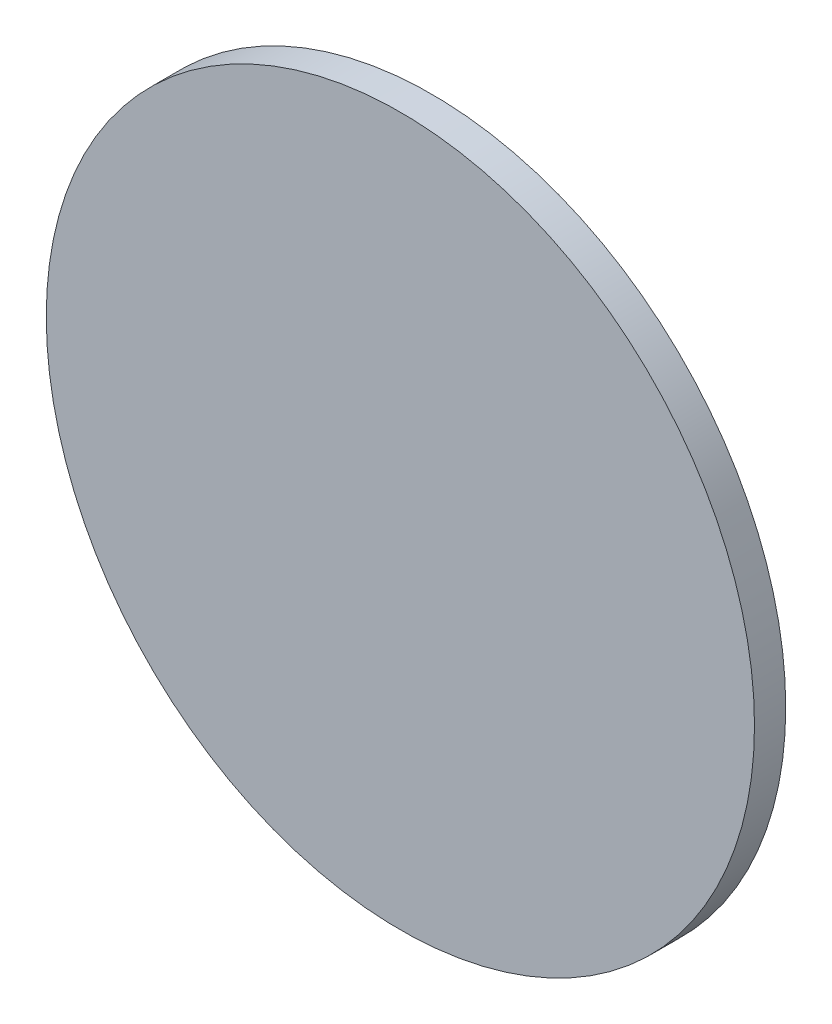
from build123d import *

# Parameters (mm, degrees)
SKETCH1_R                = 85
BOSS_EXTRUDE1_DEPTH      = 7.5
CUT_EXTRUDE1_DEPTH       = 2
SKETCH4_R                = 1
BOSS_EXTRUDE2_DEPTH      = 2
REVOLVE1_ANGLE           = 90
CIRPATTERN1_COUNT        = 3
CIRPATTERN1_COPY_1_ANGLE = 90
CIRPATTERN1_COPY_2_ANGLE = 90


with BuildPart() as part:
    # Sketch1 → Boss-Extrude1 (new body)
    with BuildSketch(Plane.XY):
        Circle(SKETCH1_R)
    extrude(amount=BOSS_EXTRUDE1_DEPTH)

    # Sketch3 → Cut-Extrude1 (cut, symmetric)
    with BuildSketch(Plane(origin=(0, 0, -92.825007953), x_dir=(0, 0, -1), z_dir=(-0.8371691043312235, -0.5469441386039866, 0))):
        with BuildLine():
            Line((-92.825007953, 82), (-92.825007953, 78))
            ThreePointArc((-92.825007953, 78), (-94.825007953, 80), (-92.825007953, 82))
        make_face()
    cut_extrude1 = extrude(amount=CUT_EXTRUDE1_DEPTH, both=True, mode=Mode.SUBTRACT)

    # Sketch4 → Boss-Extrude2 (add, symmetric)
    with BuildSketch(Plane(origin=(0, 0, -92.825007953), x_dir=(0, 0, -1), z_dir=(-0.8371691043312235, -0.5469441386039866, 0))):
        with Locations((-92.825007953, 80)):
            Circle(SKETCH4_R)
    boss_extrude2 = extrude(amount=BOSS_EXTRUDE2_DEPTH, both=True)

    # Sketch5 → Revolve1 (revolve)
    with BuildSketch(Plane(origin=(-1.674338209, -1.093888277, 0), x_dir=(0, 0, -1), z_dir=(-0.8371691043312235, -0.5469441386039867, 0))):
        with BuildLine():
            ThreePointArc((0, 79), (1, 80), (0, 81))
            Line((0, 81), (0, 79))
        make_face()
    revolve1 = revolve(axis=Axis((42.628137018, -68.904585728, 0), (-0.5469441386039868, 0.8371691043312235, 0)), revolution_arc=REVOLVE1_ANGLE)

    # Mirror1: Revolve1 across plane
    add(revolve1.mirror(Plane(origin=(0, 0, 0), x_dir=(0, 0, 1), z_dir=(0.8371691043312218, 0.5469441386039892, -2.013840245446376e-15))))

    # CirPattern1: Cut-Extrude1, Boss-Extrude2, Revolve1 ×3 about axis
    cirpattern1_axis = Axis((0, 0, 7.5), (0, 0, -1))
    add([cut_extrude1.rotate(cirpattern1_axis, i * 360 / CIRPATTERN1_COUNT) for i in range(1, CIRPATTERN1_COUNT)], mode=Mode.SUBTRACT)
    add([boss_extrude2.rotate(cirpattern1_axis, i * 360 / CIRPATTERN1_COUNT) for i in range(1, CIRPATTERN1_COUNT)])
    add([revolve1.rotate(cirpattern1_axis, i * 360 / CIRPATTERN1_COUNT) for i in range(1, CIRPATTERN1_COUNT)])

    # CirPattern1 copy 1 sketch → CirPattern1 copy 1 (revolve)
    with BuildSketch(Plane(origin=(0.110165933, -1.996963562, 0), x_dir=(0, 0, -1), z_dir=(0.055082966316444104, -0.9984817809162979, -4.022974273625351e-15))):
        with BuildLine():
            ThreePointArc((0, -79), (1, -80), (0, -81))
            Line((0, -81), (0, -79))
        make_face()
    revolve(axis=Axis((-80.766858322, -6.458683833, 0), (-0.9984817809162977, -0.05508296631644394, 0)), revolution_arc=CIRPATTERN1_COPY_1_ANGLE)

    # CirPattern1 copy 2 sketch → CirPattern1 copy 2 (revolve)
    with BuildSketch(Plane(origin=(-1.784504141, 0.903075285, 0), x_dir=(0, 0, -1), z_dir=(-0.8922520706476645, 0.45153764231230564, -4.022974273625351e-15))):
        with BuildLine():
            ThreePointArc((0, -79), (1, -80), (0, -81))
            Line((0, -81), (0, -79))
        make_face()
    revolve(axis=Axis((34.790044886, 73.175493007, 0), (0.45153764231230564, 0.8922520706476642, 0)), revolution_arc=CIRPATTERN1_COPY_2_ANGLE)

    # Sketch6 → Cut-Revolve1 (revolve, cut)
    with BuildSketch(Plane(origin=(0, 0, 0), x_dir=(0, 0, -1), z_dir=(1, 0, 0))):
        with BuildLine():
            Line((5, 0), (-5, 0))
            ThreePointArc((-5, 0), (0, 5), (5, 0))
        make_face()
    revolve(axis=Axis((0, 0, -5), (0, 0, 1)), mode=Mode.SUBTRACT)


solid = part.part
